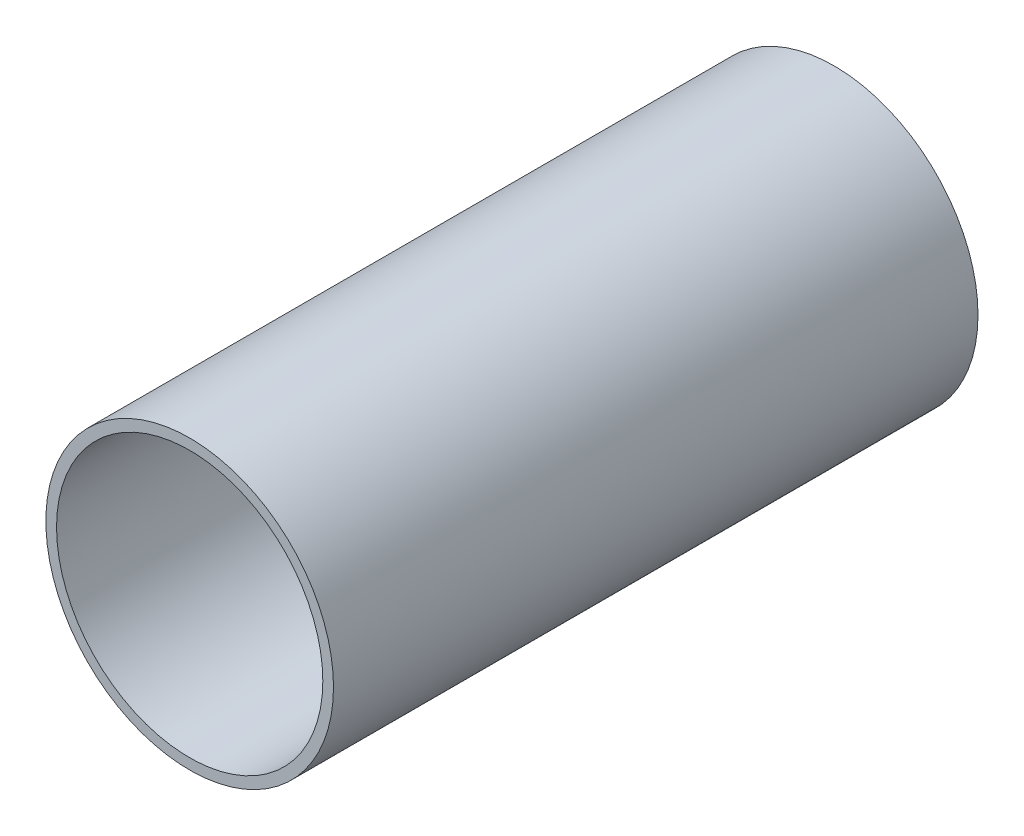
from build123d import *

# Parameters (mm, degrees)
PIPESKETCH_R    = 203.2
PIPESKETCH_R_2  = 188.1124
EXTRUSION_DEPTH = 910.6


with BuildPart() as part:
    # PipeSketch → Extrusion (new body)
    with BuildSketch(Plane.XY):
        Circle(PIPESKETCH_R)
        Circle(PIPESKETCH_R_2, mode=Mode.SUBTRACT)
    extrude(amount=EXTRUSION_DEPTH)


solid = part.part
